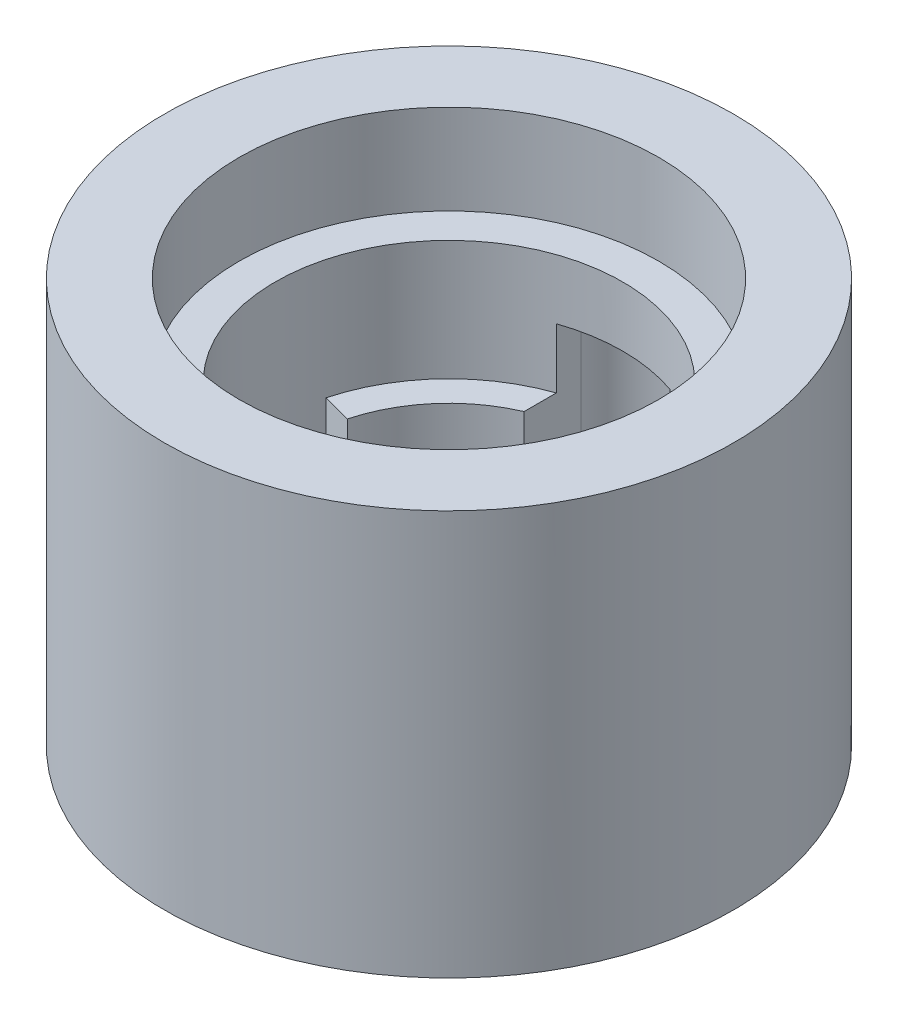
from build123d import *

# Parameters (mm, degrees)
SKETCH1_R            = 7.62
SKETCH1_R_2          = 6.096
BOSS_EXTRUDE1_DEPTH  = 10.16
SKETCH1_4_R          = 12.065
SKETCH1_4_R_2        = 7.62
BOSS_EXTRUDE2_DEPTH  = 12.7
SKETCH9_R            = 12.065
SKETCH9_R_2          = 7.62
BOSS_EXTRUDE22_DEPTH = 1.27
SKETCH10_R           = 8.89
SKETCH10_R_2         = 7.62
CUT_EXTRUDE5_DEPTH   = 3.81
SKETCH14_W           = 4.826
SKETCH14_H           = 8.001
CUT_EXTRUDE8_DEPTH   = 7.62
CUT_EXTRUDE9_DEPTH   = 5.08
SKETCH16_R           = 12.065
BOSS_EXTRUDE24_DEPTH = 3.175
SKETCH17_R           = 7.366
SKETCH17_R_2         = 6.096
CUT_EXTRUDE10_DEPTH  = 5.08
CUT_EXTRUDE11_DEPTH  = 8.255


with BuildPart() as part:
    # Sketch1 → Boss-Extrude1 (new body)
    with BuildSketch(Plane(origin=(0, 0, 0), x_dir=(1, 0, 0), z_dir=(0, 1, 0))):
        Circle(SKETCH1_R)
        Circle(SKETCH1_R_2, mode=Mode.SUBTRACT)
    extrude(amount=BOSS_EXTRUDE1_DEPTH)

    # Sketch1_4 → Boss-Extrude2 (add)
    with BuildSketch(Plane(origin=(0, 0, 0), x_dir=(1, 0, 0), z_dir=(0, 1, 0))):
        Circle(SKETCH1_4_R)
        Circle(SKETCH1_4_R_2, mode=Mode.SUBTRACT)
    extrude(amount=BOSS_EXTRUDE2_DEPTH)

    # Sketch9 → Boss-Extrude22 (add)
    with BuildSketch(Plane(origin=(0, 12.7, 0), x_dir=(1, 0, 0), z_dir=(0, 1, 0))):
        Circle(SKETCH9_R)
        Circle(SKETCH9_R_2, mode=Mode.SUBTRACT)
    extrude(amount=BOSS_EXTRUDE22_DEPTH)

    # Sketch10 → Cut-Extrude5 (cut)
    with BuildSketch(Plane(origin=(0, 13.97, 0), x_dir=(1, 0, 0), z_dir=(0, 1, 0))):
        Circle(SKETCH10_R)
        Circle(SKETCH10_R_2, mode=Mode.SUBTRACT)
    extrude(amount=-CUT_EXTRUDE5_DEPTH, mode=Mode.SUBTRACT)

    # Sketch14 → Cut-Extrude8 (cut)
    with BuildSketch(Plane.XZ):
        with Locations((0, -4.0005)):
            Rectangle(SKETCH14_W, SKETCH14_H)
    extrude(amount=-CUT_EXTRUDE8_DEPTH, mode=Mode.SUBTRACT)

    # Sketch15 → Cut-Extrude9 (cut)
    with BuildSketch(Plane.XZ.offset(-7.62)):
        with BuildLine():
            Line((2.413, -8.001), (-2.413, -8.001))
            ThreePointArc((-2.413, -8.001), (0, -10.033), (2.413, -8.001))
        make_face()
    extrude(amount=CUT_EXTRUDE9_DEPTH, mode=Mode.SUBTRACT)

    # Sketch16 → Boss-Extrude24 (add)
    with BuildSketch(Plane.XZ):
        Circle(SKETCH16_R)
        with BuildLine():
            Line((2.413, -5.598093), (2.413, -8.001))
            Line((2.413, -8.001), (-2.413, -8.001))
            Line((-2.413, -8.001), (-2.413, -5.598093))
            ThreePointArc((-2.413, -5.598093), (0, 6.096), (2.413, -5.598093))
        make_face(mode=Mode.SUBTRACT)
    extrude(amount=BOSS_EXTRUDE24_DEPTH)

    # Sketch17 → Cut-Extrude10 (cut)
    with BuildSketch(Plane(origin=(0, 10.16, 0), x_dir=(1, 0, 0), z_dir=(0, 1, 0))):
        Circle(SKETCH17_R)
        Circle(SKETCH17_R_2, mode=Mode.SUBTRACT)
    extrude(amount=-CUT_EXTRUDE10_DEPTH, mode=Mode.SUBTRACT)

    # Sketch18 → Cut-Extrude11 (cut)
    with BuildSketch(Plane(origin=(0, 5.08, 0), x_dir=(1, 0, 0), z_dir=(0, 1, 0))):
        with BuildLine():
            Line((0, 0), (-7.11501, -1.906461))
            ThreePointArc((-7.11501, -1.906461), (-7.366, 0), (-7.11501, 1.906461))
            Line((-7.11501, 1.906461), (0, 0))
        make_face()
    extrude(amount=-CUT_EXTRUDE11_DEPTH, mode=Mode.SUBTRACT)


solid = part.part
